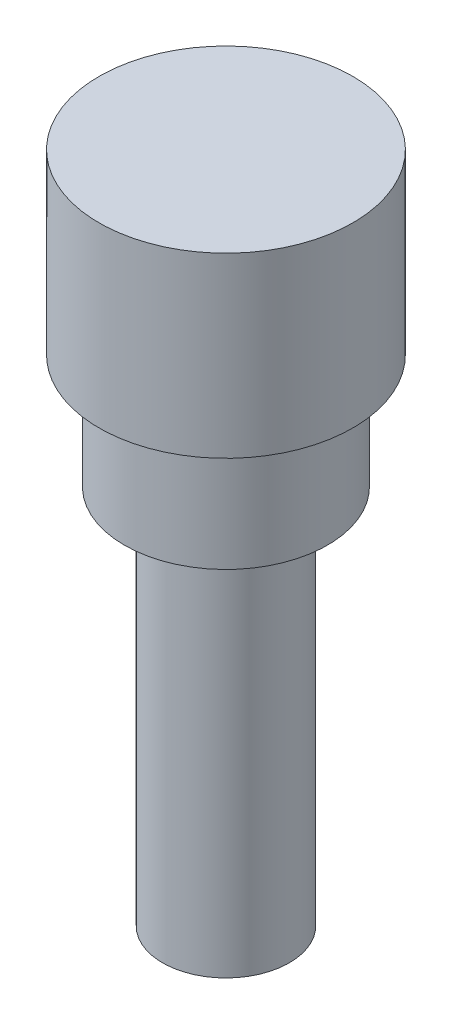
from build123d import *


with BuildPart() as part:
    # Sketch2 → Revolve1 (revolve)
    with BuildSketch(Plane.XY):
        Polygon((0, 0), (-5, 0), (-5, -7), (-4, -7), (-4, -11.5), (-2.5, -11.5), (-2.5, -26.5), (0, -26.5), align=None)
    revolve(axis=Axis((0, -26.5, 0), (0, 1, 0)))


solid = part.part
